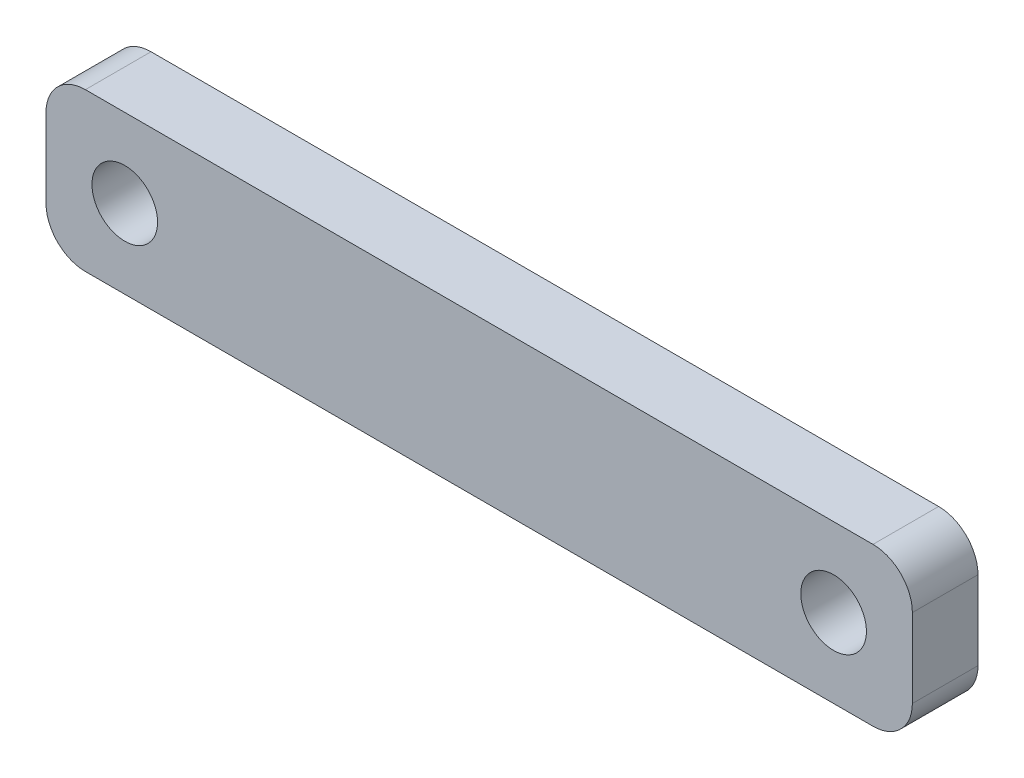
from build123d import *

# Parameters (mm, degrees)
SKETCH20_R          = 2.5
BOSS_EXTRUDE3_DEPTH = 5


with BuildPart() as part:
    # Sketch20 → Boss-Extrude3 (new body)
    with BuildSketch(Plane.XY):
        with BuildLine():
            Line((-22.066134263, -5.041150169), (37.933865737, -5.041150169))
            ThreePointArc((37.933865737, -5.041150169), (40.05518608, -5.919829825), (40.933865737, -8.041150169))
            Line((40.933865737, -8.041150169), (40.933865737, -14.041150169))
            ThreePointArc((40.933865737, -14.041150169), (40.05518608, -16.162470512), (37.933865737, -17.041150169))
            Line((37.933865737, -17.041150169), (-22.066134263, -17.041150169))
            ThreePointArc((-22.066134263, -17.041150169), (-24.187454607, -16.162470512), (-25.066134263, -14.041150169))
            Line((-25.066134263, -14.041150169), (-25.066134263, -8.041150169))
            ThreePointArc((-25.066134263, -8.041150169), (-24.187454607, -5.919829825), (-22.066134263, -5.041150169))
        make_face()
        with Locations((-19.066134263, -11.041150169)):
            Circle(SKETCH20_R, mode=Mode.SUBTRACT)
        with Locations((34.933865737, -11.041150169)):
            Circle(SKETCH20_R, mode=Mode.SUBTRACT)
    extrude(amount=BOSS_EXTRUDE3_DEPTH)


solid = part.part
